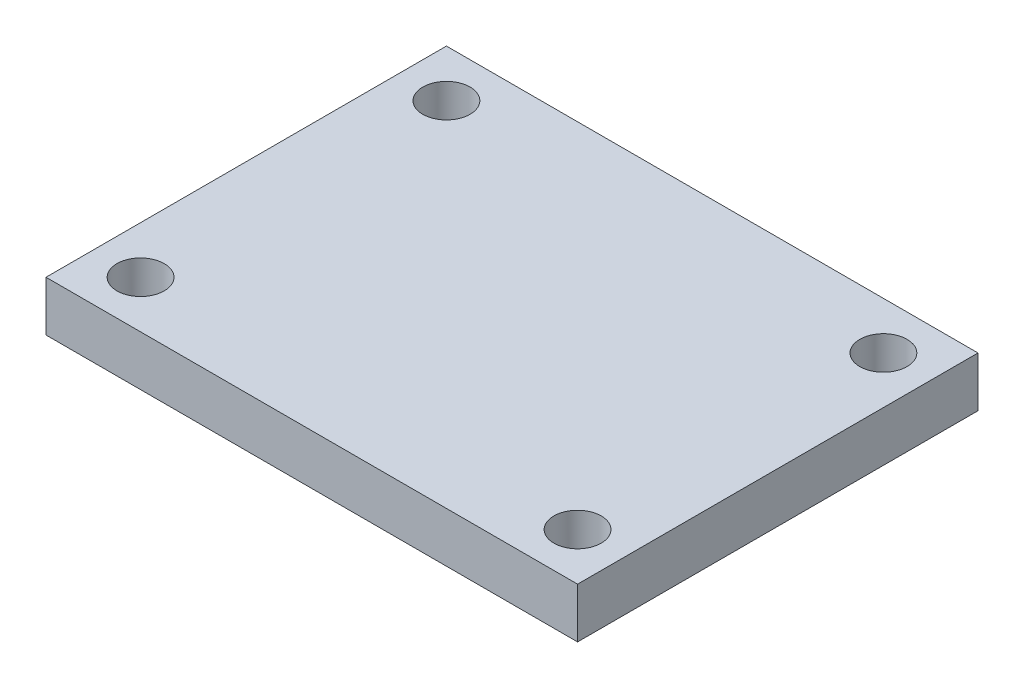
from build123d import *

# Parameters (mm, degrees)
CROQUIS1_W              = 33.7185
CROQUIS1_H              = 25.4
SALIENTE_EXTRUIR1_DEPTH = 3.175
CROQUIS3_R              = 1.5
CORTAR_EXTRUIR1_DEPTH   = 10


with BuildPart() as part:
    # Croquis1 → Saliente-Extruir1 (new body)
    with BuildSketch(Plane(origin=(0, 0, 0), x_dir=(1, 0, 0), z_dir=(0, 1, 0))):
        Rectangle(CROQUIS1_W, CROQUIS1_H)
    extrude(amount=SALIENTE_EXTRUIR1_DEPTH)

    # Croquis3 → Cortar-Extruir1 (cut)
    with BuildSketch(Plane(origin=(0, 3.175, 0), x_dir=(1, 0, 0), z_dir=(0, 1, 0))):
        with Locations((-13.85925, 9.7)):
            Circle(CROQUIS3_R)
        with Locations((-13.85925, -23.336)):
            Circle(CROQUIS3_R)
        with Locations((13.85925, -23.336)):
            Circle(CROQUIS3_R)
        with Locations((13.85925, 9.7)):
            Circle(CROQUIS3_R)
        with Locations((13.85925, -9.7)):
            Circle(CROQUIS3_R)
        with Locations((-13.85925, -9.7)):
            Circle(CROQUIS3_R)
    extrude(amount=-CORTAR_EXTRUIR1_DEPTH, mode=Mode.SUBTRACT)


solid = part.part
